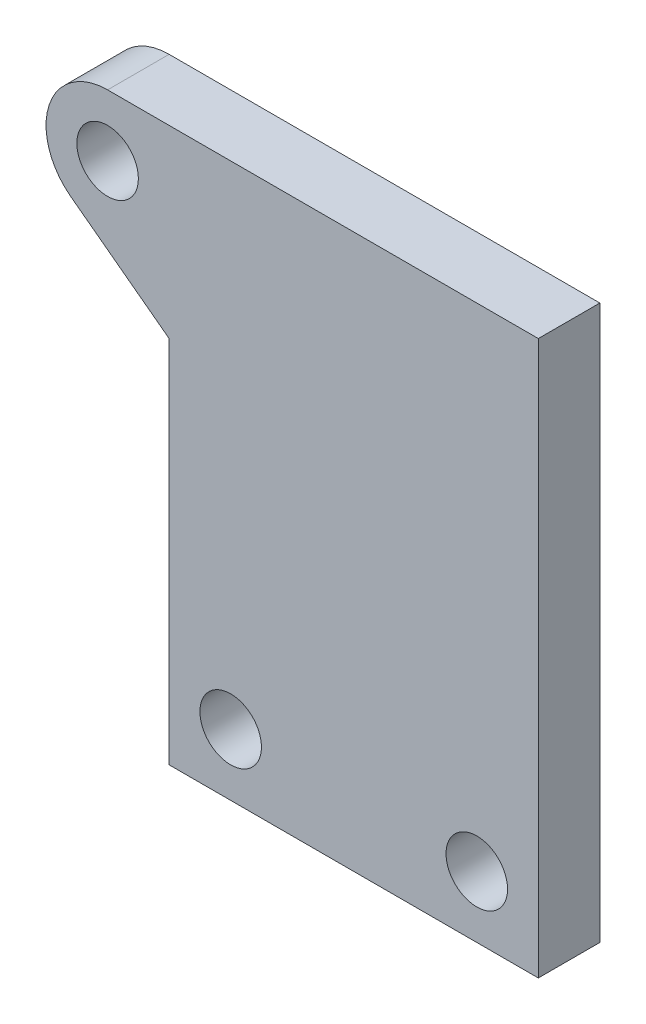
from build123d import *

# Parameters (mm, degrees)
SKETCH1_R           = 2.5
BOSS_EXTRUDE1_DEPTH = 5


with BuildPart() as part:
    # Sketch1 → Boss-Extrude1 (new body)
    with BuildSketch(Plane.XY):
        with BuildLine():
            Line((-15, -5), (15, -5))
            Line((15, -5), (15, 40))
            Line((15, 40), (-20, 40))
            ThreePointArc((-20, 40), (-23.535533906, 38.535533906), (-25, 35))
            ThreePointArc((-25, 35), (-24.472135955, 32.763932023), (-23, 31))
            Line((-23, 31), (-15, 25))
            Line((-15, 25), (-15, -5))
        make_face()
        with Locations((-10, 0)):
            Circle(SKETCH1_R, mode=Mode.SUBTRACT)
        with Locations((10, 0)):
            Circle(SKETCH1_R, mode=Mode.SUBTRACT)
        with Locations((-20, 35)):
            Circle(SKETCH1_R, mode=Mode.SUBTRACT)
    extrude(amount=BOSS_EXTRUDE1_DEPTH)


solid = part.part
